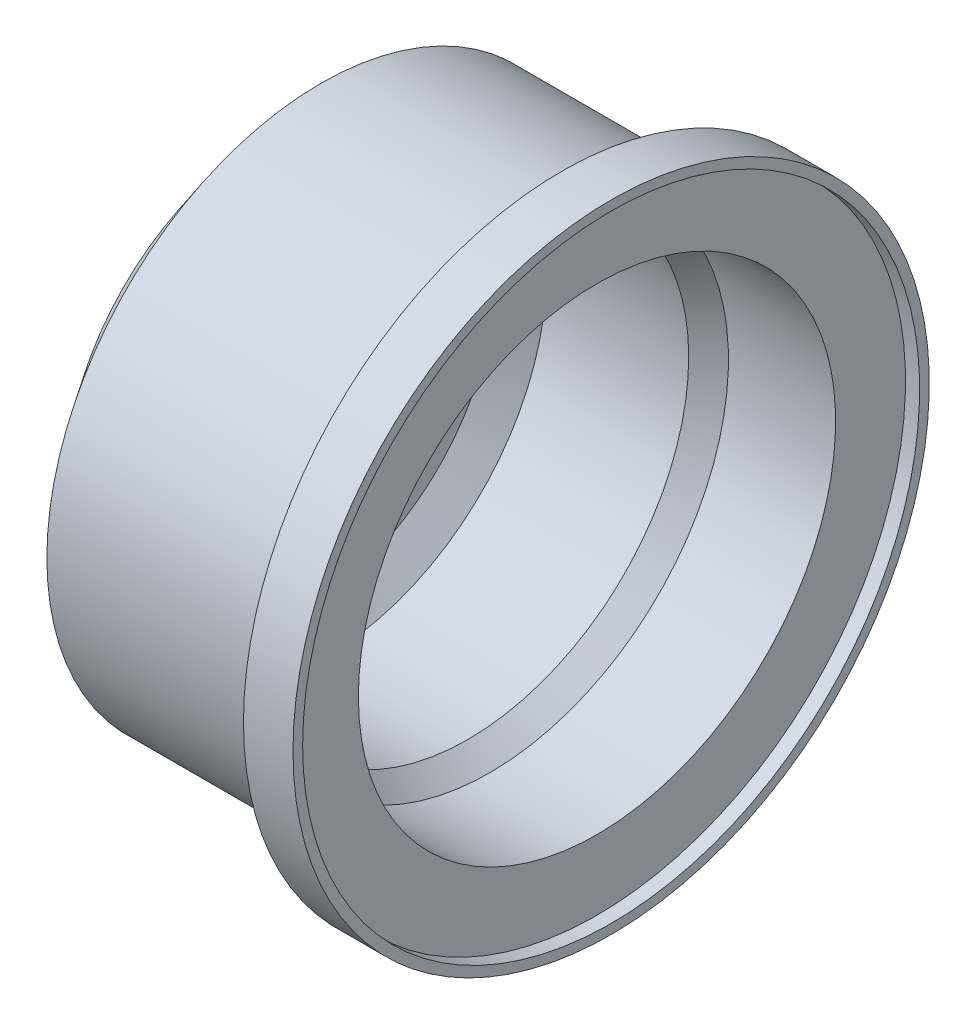
from build123d import *

# Parameters (mm, degrees)
SKETCH2_R           = 5
CUT_EXTRUDE1_DEPTH  = 10
BOSS_EXTRUDE1_DEPTH = 0.5


with BuildPart() as part:
    # Sketch1 → Revolve1 (revolve)
    with BuildSketch(Plane.XY):
        Polygon((-13.622037679, 15.5), (0, 15.5), (0, 18), (2, 18), (2.8, 18), (2.8, 17.453091715), (2, 17.453091715), (2, 13.5), (-4.063478188, 13.5), (-5.311018839, 12.5), (-13.372037679, 12.5), (-14.622037679, 10.833333333), (-14.622037679, 0), (-16.622037679, 0), (-16.622037679, 11.5), align=None)
    revolve(axis=Axis((-25, 0, 0), (1, 0, 0)))

    # Sketch2 → Cut-Extrude1 (cut)
    with BuildSketch(Plane.ZY.offset(16.622037679)):
        Circle(SKETCH2_R)
    extrude(amount=-CUT_EXTRUDE1_DEPTH, mode=Mode.SUBTRACT)

    # Sketch3 → Boss-Extrude1 (add)
    with BuildSketch(Plane(origin=(-14.622037679, 0, 0), x_dir=(0, 0, -1), z_dir=(1, 0, 0))):
        Polygon((7.134838542, 3.062100229), (7.975608442, 3.633882224), (7.900815659, 4.647901314), (6.985252976, 5.090138409), (6.144483075, 4.518356414), (6.219275858, 3.504337324), align=None)
        Polygon((0.915562683, 7.710001544), (0.8407699, 8.724020633), (-0.074792783, 9.166257728), (-0.915562683, 8.594475733), (-0.8407699, 7.580456643), (0.074792783, 7.138219548), align=None)
        Polygon((6.219275858, -4.647901314), (7.134838542, -5.090138409), (7.975608442, -4.518356414), (7.900815659, -3.504337324), (6.985252976, -3.062100229), (6.144483075, -3.633882224), align=None)
        Polygon((-0.915562683, -7.710001544), (-0.8407699, -8.724020633), (0.074792783, -9.166257728), (0.915562683, -8.594475733), (0.8407699, -7.580456643), (-0.074792783, -7.138219548), align=None)
        Polygon((-7.134838542, -3.062100229), (-7.975608442, -3.633882224), (-7.900815659, -4.647901314), (-6.985252976, -5.090138409), (-6.144483075, -4.518356414), (-6.219275858, -3.504337324), align=None)
        Polygon((-6.219275858, 4.647901314), (-7.134838542, 5.090138409), (-7.975608442, 4.518356414), (-7.900815659, 3.504337324), (-6.985252976, 3.062100229), (-6.144483075, 3.633882224), align=None)
    extrude(amount=BOSS_EXTRUDE1_DEPTH)


solid = part.part
